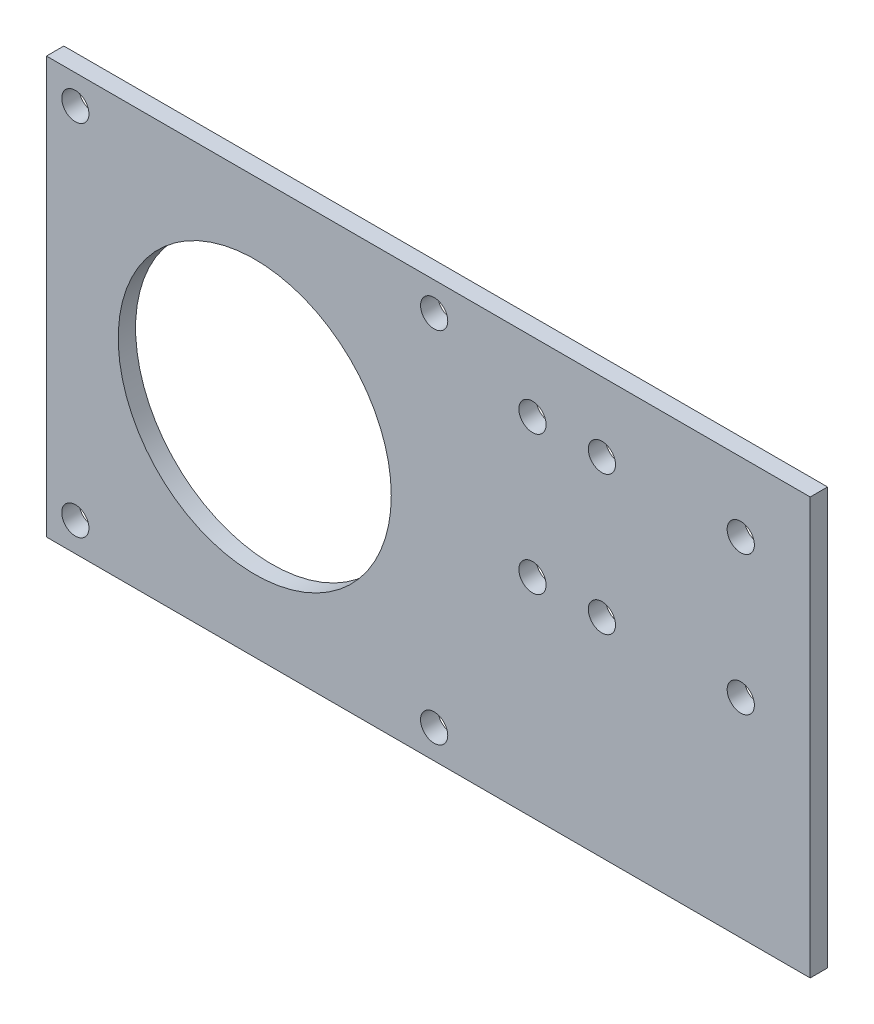
from build123d import *

# Parameters (mm, degrees)
SKETCH1_W           = 139.7
SKETCH1_H           = 76.2
SKETCH1_R           = 2.4892
SKETCH1_R_2         = 24.97201
BOSS_EXTRUDE1_DEPTH = 3.175


with BuildPart() as part:
    # Sketch1 → Boss-Extrude1 (new body)
    with BuildSketch(Plane.XY):
        with Locations((-44.45, 151.48179)):
            Rectangle(SKETCH1_W, SKETCH1_H)
        with Locations((-109.0168, 118.66499)):
            Circle(SKETCH1_R, mode=Mode.SUBTRACT)
        with Locations((-76.2, 151.48179)):
            Circle(SKETCH1_R_2, mode=Mode.SUBTRACT)
        with Locations((-43.3832, 184.29859)):
            Circle(SKETCH1_R, mode=Mode.SUBTRACT)
        with Locations((-25.4, 151.48179)):
            Circle(SKETCH1_R, mode=Mode.SUBTRACT)
        with Locations((-25.4, 176.88179)):
            Circle(SKETCH1_R, mode=Mode.SUBTRACT)
        with Locations((-12.7, 151.48179)):
            Circle(SKETCH1_R, mode=Mode.SUBTRACT)
        with Locations((-12.7, 176.88179)):
            Circle(SKETCH1_R, mode=Mode.SUBTRACT)
        with Locations((12.7, 151.48179)):
            Circle(SKETCH1_R, mode=Mode.SUBTRACT)
        with Locations((12.7, 176.88179)):
            Circle(SKETCH1_R, mode=Mode.SUBTRACT)
        with Locations((-109.0168, 184.29859)):
            Circle(SKETCH1_R, mode=Mode.SUBTRACT)
        with Locations((-43.3832, 118.66499)):
            Circle(SKETCH1_R, mode=Mode.SUBTRACT)
    extrude(amount=BOSS_EXTRUDE1_DEPTH)


solid = part.part
